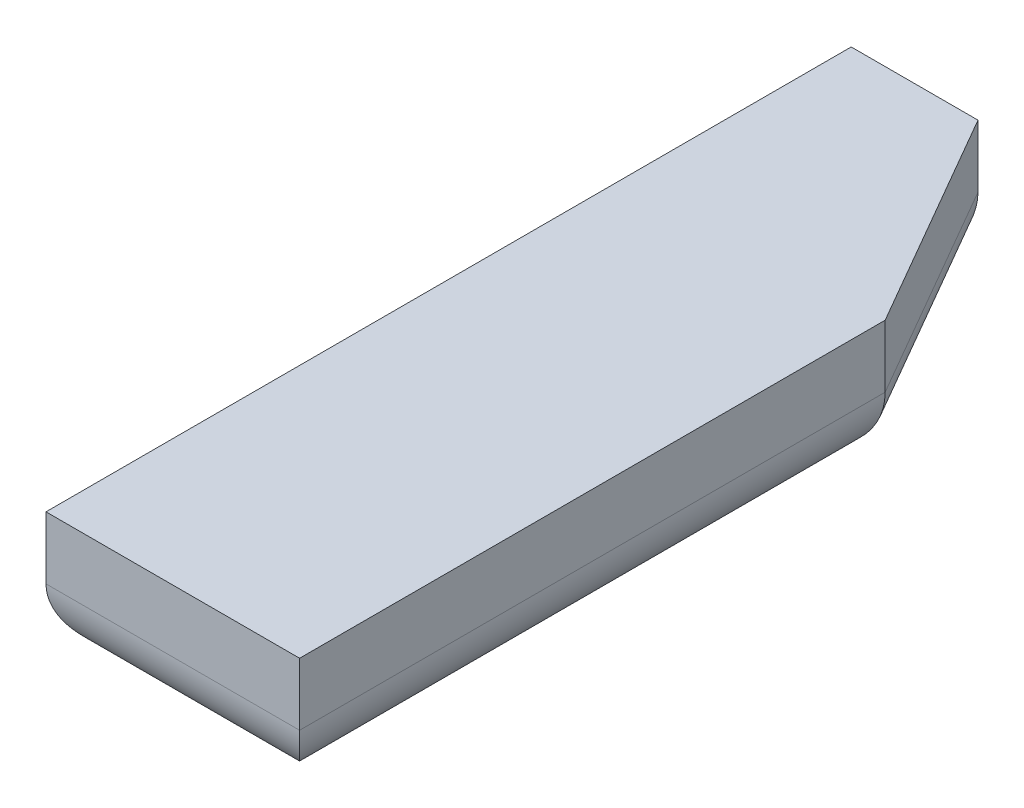
from build123d import *

# Parameters (mm, degrees)
BOSS_EXTRUDE1_DEPTH = 10
FILLET1_R           = 5.08


with BuildPart() as part:
    # Sketch1 → Boss-Extrude1 (new body)
    with BuildSketch(Plane(origin=(0, 0, 0), x_dir=(1, 0, 0), z_dir=(0, 1, 0))):
        Polygon((10, -31.75), (10, 14.429491924), (0, 31.75), (-10, 31.75), (-10, -31.75), align=None)
    extrude(amount=BOSS_EXTRUDE1_DEPTH)

    # Fillet1
    fillet1_edges = [part.edges().sort_by_distance(p)[0] for p in [
        (-10, 0, 0),
        (-5, 0, -31.75),
        (5, 0, -23.089745962),
        (10, 0, 8.660254038),
        (0, 0, 31.75),
    ]]
    fillet(fillet1_edges, radius=FILLET1_R)


solid = part.part
